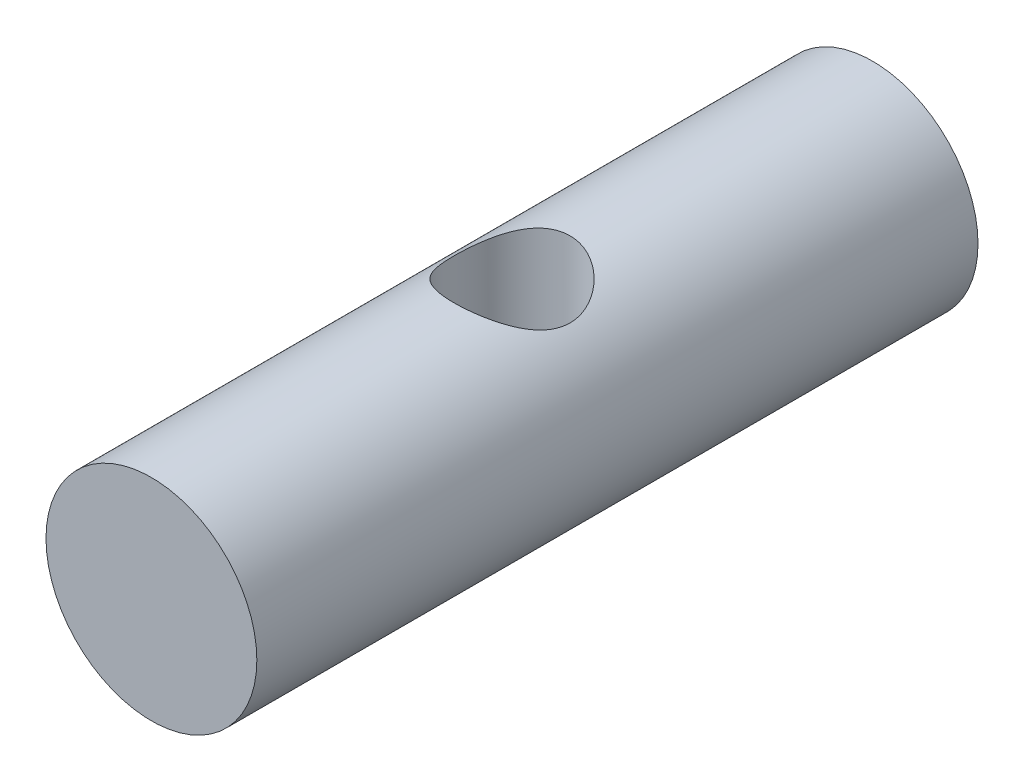
from build123d import *

# Parameters (mm, degrees)
SKETCH1_R           = 1.7526
BOSS_EXTRUDE1_DEPTH = 5.9944
SKETCH2_R           = 0.9652
CUT_EXTRUDE1_DEPTH  = 3.4544


with BuildPart() as part:
    # Sketch1 → Boss-Extrude1 (new body, symmetric)
    with BuildSketch(Plane.XY):
        Circle(SKETCH1_R)
    extrude(amount=BOSS_EXTRUDE1_DEPTH, both=True)

    # Sketch2 → Cut-Extrude1 (cut, symmetric)
    with BuildSketch(Plane(origin=(0, 0, 0), x_dir=(1, 0, 0), z_dir=(0, 1, 0))):
        Circle(SKETCH2_R)
    extrude(amount=CUT_EXTRUDE1_DEPTH, both=True, mode=Mode.SUBTRACT)


solid = part.part
